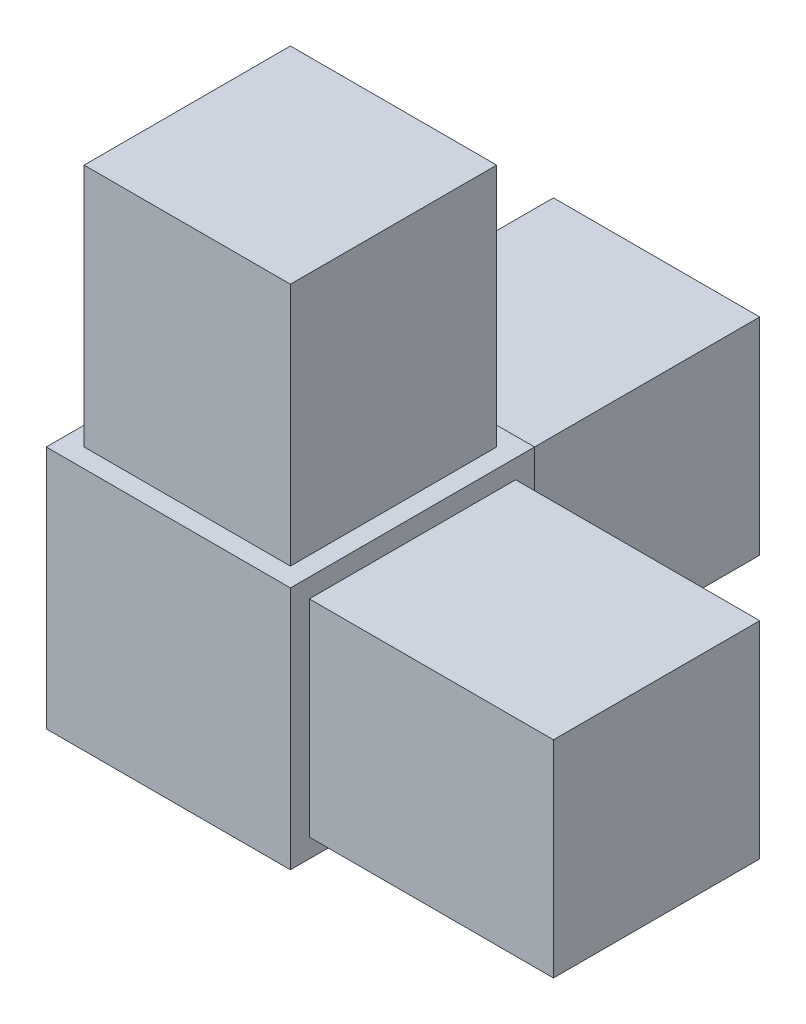
from build123d import *

# Parameters (mm, degrees)
SKETCH1_W           = 20
SKETCH1_H           = 20
BOSS_EXTRUDE1_DEPTH = 20
SKETCH2_W           = 16.9
SKETCH2_H           = 16.9
BOSS_EXTRUDE2_DEPTH = 20
SKETCH3_W           = 16.9
SKETCH3_H           = 16.9
BOSS_EXTRUDE3_DEPTH = 20
SKETCH4_W           = 16.9
SKETCH4_H           = 16.9
BOSS_EXTRUDE4_DEPTH = 20


with BuildPart() as part:
    # Sketch1 → Boss-Extrude1 (new body)
    with BuildSketch(Plane(origin=(0, 0, 0), x_dir=(1, 0, 0), z_dir=(0, 1, 0))):
        Rectangle(SKETCH1_W, SKETCH1_H)
    extrude(amount=BOSS_EXTRUDE1_DEPTH)

    # Sketch2 → Boss-Extrude2 (add)
    with BuildSketch(Plane(origin=(0, 20, 0), x_dir=(1, 0, 0), z_dir=(0, 1, 0))):
        Rectangle(SKETCH2_W, SKETCH2_H)
    extrude(amount=BOSS_EXTRUDE2_DEPTH)

    # Sketch3 → Boss-Extrude3 (add)
    with BuildSketch(Plane(origin=(10, 0, 0), x_dir=(0, 0, -1), z_dir=(1, 0, 0))):
        with Locations((0, 10)):
            Rectangle(SKETCH3_W, SKETCH3_H)
    extrude(amount=BOSS_EXTRUDE3_DEPTH)

    # Sketch4 → Boss-Extrude4 (add)
    with BuildSketch(Plane(origin=(0, 0, -10), x_dir=(-1, 0, 0), z_dir=(0, 0, -1))):
        with Locations((0, 10)):
            Rectangle(SKETCH4_W, SKETCH4_H)
    extrude(amount=BOSS_EXTRUDE4_DEPTH)


solid = part.part
